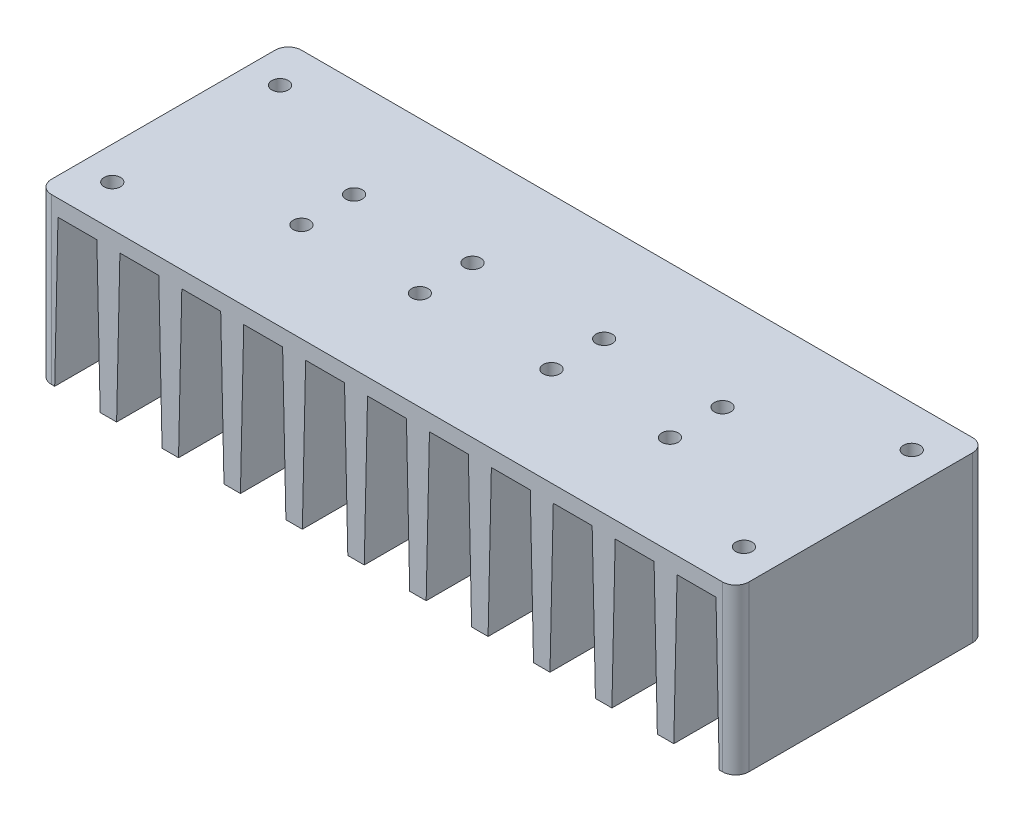
from build123d import *

# Parameters (mm, degrees)
SKETCH1_W           = 212
SKETCH1_H           = 76
BOSS_EXTRUDE1_DEPTH = 50
CUT_EXTRUDE1_DEPTH  = 77
SKETCH4_R           = 2.5
CUT_EXTRUDE2_DEPTH  = 77
FILLET1_R           = 4


with BuildPart() as part:
    # Sketch1 → Boss-Extrude1 (new body)
    with BuildSketch(Plane(origin=(0, 0, 0), x_dir=(1, 0, 0), z_dir=(0, 1, 0))):
        Rectangle(SKETCH1_W, SKETCH1_H)
    extrude(amount=BOSS_EXTRUDE1_DEPTH)

    # Sketch2 → Cut-Extrude1 (cut)
    with BuildSketch(Plane.XY.offset(38)):
        Polygon((101, 0), (100, 45), (88.181819, 45), (87.181819, 0), align=None)
        Polygon((68.363638, 0), (82.181819, 0), (81.181819, 45), (69.363638, 45), align=None)
        Polygon((49.545457, 0), (63.363638, 0), (62.363638, 45), (50.545457, 45), align=None)
        Polygon((30.727276, 0), (44.545457, 0), (43.545457, 45), (31.727276, 45), align=None)
        Polygon((11.909095, 0), (25.727276, 0), (24.727276, 45), (12.909095, 45), align=None)
        Polygon((-6.909086, 0), (6.909095, 0), (5.909095, 45), (-5.909086, 45), align=None)
        Polygon((-25.727267, 0), (-11.909086, 0), (-12.909086, 45), (-24.727267, 45), align=None)
        Polygon((-44.545448, 0), (-30.727267, 0), (-31.727267, 45), (-43.545448, 45), align=None)
        Polygon((-63.363629, 0), (-49.545448, 0), (-50.545448, 45), (-62.363629, 45), align=None)
        Polygon((-82.18181, 0), (-68.363629, 0), (-69.363629, 45), (-81.18181, 45), align=None)
        Polygon((-100.999991, 0), (-87.18181, 0), (-88.18181, 45), (-99.999991, 45), align=None)
    extrude(amount=-CUT_EXTRUDE1_DEPTH, mode=Mode.SUBTRACT)

    # Sketch4 → Cut-Extrude2 (cut)
    with BuildSketch(Plane(origin=(0, 50, 0), x_dir=(1, 0, 0), z_dir=(0, 1, 0))):
        with Locations((-96, 25.5)):
            Circle(SKETCH4_R)
        with Locations((-96, -25.5)):
            Circle(SKETCH4_R)
        with Locations((96, 25.5)):
            Circle(SKETCH4_R)
        with Locations((96, -25.5)):
            Circle(SKETCH4_R)
        with Locations((-56, 8)):
            Circle(SKETCH4_R)
        with Locations((-20, 8)):
            Circle(SKETCH4_R)
        with Locations((-20, -8)):
            Circle(SKETCH4_R)
        with Locations((-56, -8)):
            Circle(SKETCH4_R)
        with Locations((56, -8)):
            Circle(SKETCH4_R)
        with Locations((20, -8)):
            Circle(SKETCH4_R)
        with Locations((20, 8)):
            Circle(SKETCH4_R)
        with Locations((56, 8)):
            Circle(SKETCH4_R)
    extrude(amount=-CUT_EXTRUDE2_DEPTH, mode=Mode.SUBTRACT)

    # Fillet1
    fillet1_edges = [part.edges().sort_by_distance(p)[0] for p in [
        (106, 25, 38),
        (-106, 25, 38),
        (-106, 25, -38),
        (106, 25, -38),
    ]]
    fillet(fillet1_edges, radius=FILLET1_R)


solid = part.part
